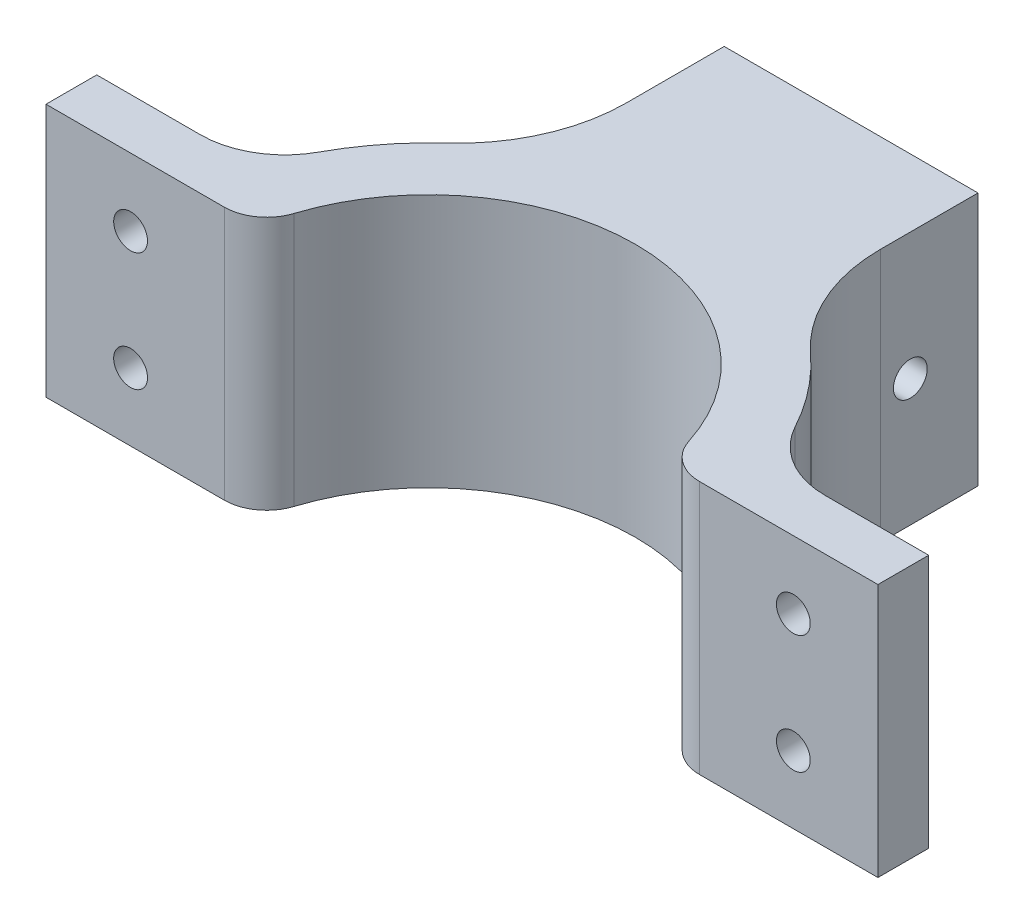
from build123d import *

# Parameters (mm, degrees)
BOSS_EXTRUDE1_DEPTH = 30
SKETCH2_R           = 2
CUT_EXTRUDE1_DEPTH  = 7
FILLET1_R           = 10
FILLET2_R           = 5
BOSS_EXTRUDE2_START = 15
SKETCH3_W           = 30
SKETCH3_H           = 30
SKETCH3_W_2         = 18.5
SKETCH3_H_2         = 18.5
BOSS_EXTRUDE2_DEPTH = 25
FILLET3_R           = 20
SKETCH4_R           = 2
CUT_EXTRUDE2_DEPTH  = 30


with BuildPart() as part:
    # Sketch1 → Boss-Extrude1 (new body)
    with BuildSketch(Plane(origin=(0, 0, 0), x_dir=(1, 0, 0), z_dir=(0, 1, 0))):
        with BuildLine():
            ThreePointArc((-24.171263931, 4), (0, 24.5), (24.171263931, 4))
            Line((24.171263931, 4), (49.171263931, 4))
            Line((49.171263931, 4), (49.171263931, 10))
            Line((49.171263931, 10), (30.397368307, 10))
            ThreePointArc((30.397368307, 10), (0, 32), (-30.397368307, 10))
            Line((-30.397368307, 10), (-49.171263931, 10))
            Line((-49.171263931, 10), (-49.171263931, 4))
            Line((-49.171263931, 4), (-24.171263931, 4))
        make_face()
    extrude(amount=BOSS_EXTRUDE1_DEPTH)

    # Sketch2 → Cut-Extrude1 (cut, through all)
    with BuildSketch(Plane(origin=(0, 0, -10), x_dir=(-1, 0, 0), z_dir=(0, 0, -1))):
        with Locations((-39.171263931, 22)):
            Circle(SKETCH2_R)
        with Locations((-39.171263931, 8)):
            Circle(SKETCH2_R)
        with Locations((39.171263931, 8)):
            Circle(SKETCH2_R)
        with Locations((39.171263931, 22)):
            Circle(SKETCH2_R)
    extrude(amount=-CUT_EXTRUDE1_DEPTH, mode=Mode.SUBTRACT)

    # Fillet1
    fillet1_edges = [part.edges().sort_by_distance(p)[0] for p in [
        (-30.397368307, 15, -10),
        (30.397368307, 15, -10),
    ]]
    fillet(fillet1_edges, radius=FILLET1_R)

    # Fillet2
    fillet2_edges = [part.edges().sort_by_distance(p)[0] for p in [
        (-24.171263931, 15, -4),
        (24.171263931, 15, -4),
    ]]
    fillet(fillet2_edges, radius=FILLET2_R)

    # Sketch3 → Boss-Extrude2 (add)
    with BuildSketch(Plane(origin=(0, 0, -10), x_dir=(-1, 0, 0), z_dir=(0, 0, -1)).offset(BOSS_EXTRUDE2_START)):
        with Locations((0, 15)):
            Rectangle(SKETCH3_W, SKETCH3_H)
        with Locations((0, 15)):
            Rectangle(SKETCH3_W_2, SKETCH3_H_2, mode=Mode.SUBTRACT)
    extrude(amount=BOSS_EXTRUDE2_DEPTH)

    # Fillet3
    fillet3_edges = [part.edges().sort_by_distance(p)[0] for p in [
        (-15, 15, -28.26658805),
        (15, 15, -28.26658805),
    ]]
    fillet(fillet3_edges, radius=FILLET3_R)

    # Sketch4 → Cut-Extrude2 (cut)
    with BuildSketch(Plane(origin=(15, 0, 0), x_dir=(0, 0, -1), z_dir=(1, 0, 0))):
        with Locations((42, 15)):
            Circle(SKETCH4_R)
    extrude(amount=-CUT_EXTRUDE2_DEPTH, mode=Mode.SUBTRACT)


solid = part.part
